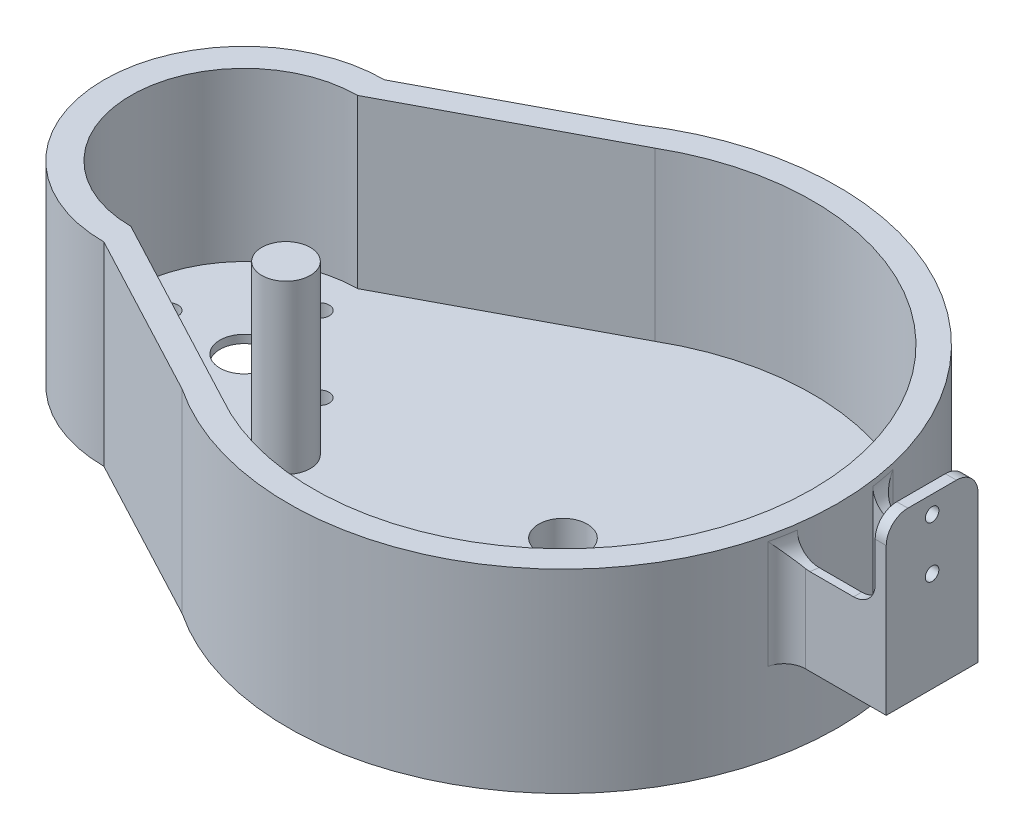
from build123d import *

# Parameters (mm, degrees)
SKETCH2_R           = 4.5
BOSS_EXTRUDE1_DEPTH = 5
BOSS_EXTRUDE4_DEPTH = 31
BOSS_EXTRUDE5_DEPTH = 31
BOSS_EXTRUDE6_DEPTH = 31
SKETCH5_W           = 2.05
SKETCH5_H           = 17
BOSS_EXTRUDE7_DEPTH = 15.25
CUT_EXTRUDE3_DEPTH  = 5
CUT_EXTRUDE4_DEPTH  = 15
FILLET2_R           = 4
SKETCH8_R           = 1.75
CUT_EXTRUDE5_DEPTH  = 10
SKETCH8_3_R         = 11.5
SKETCH8_3_R_2       = 4.5
CUT_EXTRUDE6_DEPTH  = 3.5
BOSS_EXTRUDE8_DEPTH = 31


with BuildPart() as part:
    # Sketch2 → Boss-Extrude1 (new body)
    with BuildSketch(Plane(origin=(0, 0, 0), x_dir=(1, 0, 0), z_dir=(0, 1, 0))):
        with BuildLine():
            Line((30.852324511, 42.360372936), (0, 26))
            ThreePointArc((0, 26), (-26, 0), (0, -26))
            Line((0, -26), (30.852324511, -42.360372936))
            ThreePointArc((30.852324511, -42.360372936), (109.945, 0), (30.852324511, 42.360372936))
        make_face()
        Circle(SKETCH2_R, mode=Mode.SUBTRACT)
        with Locations((59.055, 0)):
            Circle(SKETCH2_R, mode=Mode.SUBTRACT)
    extrude(amount=BOSS_EXTRUDE1_DEPTH)

    # Sketch3 → Boss-Extrude4 (add)
    with BuildSketch(Plane(origin=(0, 5, 0), x_dir=(1, 0, 0), z_dir=(0, 1, 0))):
        with BuildLine():
            Line((30.852324511, 42.360372936), (0, 26))
            ThreePointArc((0, 26), (-26, 0), (0, -26))
            Line((0, -26), (30.852324511, -42.360372936))
            ThreePointArc((30.852324511, -42.360372936), (109.945, 0), (30.852324511, 42.360372936))
        make_face()
        with BuildLine():
            ThreePointArc((0, -21), (-21, 0), (0, 21))
            Line((0, 21), (35.989825914, 40.084687562))
            ThreePointArc((35.989825914, 40.084687562), (71.67744287, 44.491104375), (99.734041687, 22))
            Line((99.734041687, 22), (102, 22))
            Line((102, 22), (102, 17.161334667))
            ThreePointArc((102, 17.161334667), (105.301993768, 0), (102, -17.161334667))
            Line((102, -17.161334667), (102, -22))
            Line((102, -22), (99.734041687, -22))
            ThreePointArc((99.734041687, -22), (71.67744287, -44.491104375), (35.989825914, -40.084687562))
            Line((35.989825914, -40.084687562), (0, -21))
        make_face(mode=Mode.SUBTRACT)
    extrude(amount=BOSS_EXTRUDE4_DEPTH)

    # Sketch3_10 → Boss-Extrude5 (add)
    with BuildSketch(Plane(origin=(0, 5, 0), x_dir=(1, 0, 0), z_dir=(0, 1, 0))):
        with BuildLine():
            Line((102, 22), (99.734041687, 22))
            ThreePointArc((99.734041687, 22), (100.936956229, 19.613418238), (102, 17.161334667))
            Line((102, 17.161334667), (102, 22))
        make_face()
        with BuildLine():
            ThreePointArc((102, -17.161334667), (100.936956229, -19.613418238), (99.734041687, -22))
            Line((99.734041687, -22), (102, -22))
            Line((102, -22), (102, -17.161334667))
        make_face()
    extrude(amount=BOSS_EXTRUDE5_DEPTH)

    # Sketch2_6 → Boss-Extrude6 (add)
    with BuildSketch(Plane(origin=(0, 0, 0), x_dir=(1, 0, 0), z_dir=(0, 1, 0))):
        with BuildLine():
            Line((127.435, 8.5), (109.23011435, 8.5))
            ThreePointArc((109.23011435, 8.5), (109.351284572, 7.750861777), (109.461270443, 7))
            Line((109.461270443, 7), (125.385, 7))
            Line((125.385, 7), (125.385, 0))
            Line((125.385, 0), (127.435, 0))
            Line((127.435, 0), (127.435, 8.5))
        make_face()
        with BuildLine():
            Line((127.435, -8.5), (127.435, 0))
            Line((127.435, 0), (125.385, 0))
            Line((125.385, 0), (125.385, -7))
            Line((125.385, -7), (109.461270443, -7))
            ThreePointArc((109.461270443, -7), (109.351284572, -7.750861777), (109.23011435, -8.5))
            Line((109.23011435, -8.5), (127.435, -8.5))
        make_face()
    extrude(amount=BOSS_EXTRUDE6_DEPTH)

    # Sketch5 → Boss-Extrude7 (add)
    with BuildSketch(Plane(origin=(0, 31, 0), x_dir=(1, 0, 0), z_dir=(0, 1, 0))):
        with Locations((126.41, 0)):
            Rectangle(SKETCH5_W, SKETCH5_H)
    extrude(amount=BOSS_EXTRUDE7_DEPTH)

    # Sketch6 → Cut-Extrude3 (cut)
    with BuildSketch(Plane(origin=(127.435, 0, 0), x_dir=(0, 0, -1), z_dir=(1, 0, 0))):
        with BuildLine():
            ThreePointArc((1.25, 43), (0.883883476, 43.883883476), (0, 44.25))
            Line((0, 44.25), (0, 41.75))
            ThreePointArc((0, 41.75), (0.883883476, 42.116116524), (1.25, 43))
        make_face()
        with BuildLine():
            Line((0, 41.75), (0, 44.25))
            ThreePointArc((0, 44.25), (-1.25, 43), (0, 41.75))
        make_face()
        with BuildLine():
            ThreePointArc((1.25, 33.5), (0.883883476, 34.383883476), (0, 34.75))
            Line((0, 34.75), (0, 32.25))
            ThreePointArc((0, 32.25), (0.883883476, 32.616116524), (1.25, 33.5))
        make_face()
        with BuildLine():
            Line((0, 32.25), (0, 34.75))
            ThreePointArc((0, 34.75), (-1.25, 33.5), (0, 32.25))
        make_face()
    extrude(amount=-CUT_EXTRUDE3_DEPTH, mode=Mode.SUBTRACT)

    # Sketch2_7 → Cut-Extrude4 (cut)
    with BuildSketch(Plane(origin=(0, 0, 0), x_dir=(1, 0, 0), z_dir=(0, 1, 0))):
        with BuildLine():
            Line((127.435, -8.5), (127.435, 0))
            Line((127.435, 0), (125.385, 0))
            Line((125.385, 0), (125.385, -7))
            Line((125.385, -7), (109.461270443, -7))
            ThreePointArc((109.461270443, -7), (109.351284572, -7.750861777), (109.23011435, -8.5))
            Line((109.23011435, -8.5), (127.435, -8.5))
        make_face()
        with BuildLine():
            Line((127.435, 8.5), (109.23011435, 8.5))
            ThreePointArc((109.23011435, 8.5), (109.351284572, 7.750861777), (109.461270443, 7))
            Line((109.461270443, 7), (125.385, 7))
            Line((125.385, 7), (125.385, 0))
            Line((125.385, 0), (127.435, 0))
            Line((127.435, 0), (127.435, 8.5))
        make_face()
    extrude(amount=CUT_EXTRUDE4_DEPTH, mode=Mode.SUBTRACT)

    # Fillet2
    fillet2_edges = [part.edges().sort_by_distance(p)[0] for p in [
        (125.385, 31, 7.75),
        (125.385, 31, -7.75),
        (126.41, 46.25, -8.5),
        (126.41, 46.25, 8.5),
        (109.351284572, 31, -7.750861777),
        (109.23011435, 23, -8.5),
        (109.351284572, 31, 7.750861777),
        (109.23011435, 23, 8.5),
    ]]
    fillet(fillet2_edges, radius=FILLET2_R)

    # Sketch8 → Cut-Extrude5 (cut)
    with BuildSketch(Plane.XZ):
        with Locations((0, 14)):
            Circle(SKETCH8_R)
        with Locations((14, 0)):
            Circle(SKETCH8_R)
        with Locations((0, -14)):
            Circle(SKETCH8_R)
        with Locations((-14, 0)):
            Circle(SKETCH8_R)
    extrude(amount=-CUT_EXTRUDE5_DEPTH, mode=Mode.SUBTRACT)

    # Sketch8_3 → Cut-Extrude6 (cut)
    with BuildSketch(Plane.XZ):
        Circle(SKETCH8_3_R)
        Circle(SKETCH8_3_R_2, mode=Mode.SUBTRACT)
    extrude(amount=-CUT_EXTRUDE6_DEPTH, mode=Mode.SUBTRACT)

    # Sketch3_13 → Boss-Extrude8 (add)
    with BuildSketch(Plane(origin=(0, 5, 0), x_dir=(1, 0, 0), z_dir=(0, 1, 0))):
        with BuildLine():
            ThreePointArc((24.5, -12.260820261), (23.824264635, -9.889112016), (22, -8.229691387))
            Line((22, -8.229691387), (22, -16.291949135))
            ThreePointArc((22, -16.291949135), (23.824264635, -14.632528506), (24.5, -12.260820261))
        make_face()
        with BuildLine():
            Line((22, -16.291949135), (22, -8.229691387))
            ThreePointArc((22, -8.229691387), (15.5, -12.260820261), (22, -16.291949135))
        make_face()
    extrude(amount=BOSS_EXTRUDE8_DEPTH)


solid = part.part
